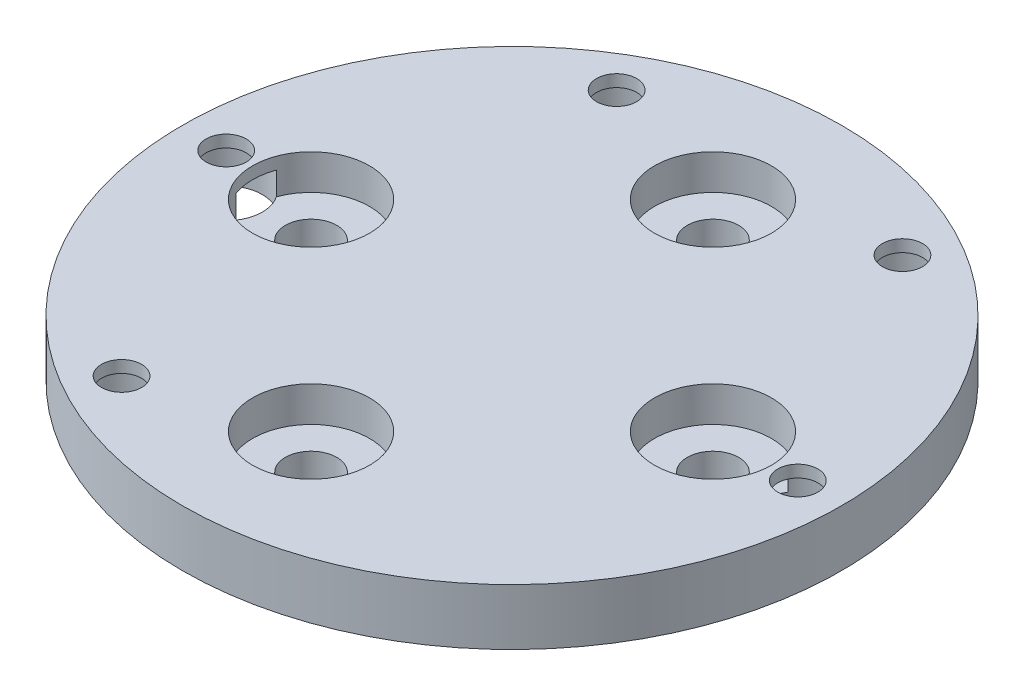
from build123d import *

# Parameters (mm, degrees)
SKETCH1_R                               = 41
BOSS_EXTRUDE1_DEPTH                     = 7
CBORE_FOR_M6_HEX_HEAD_BOLT1_D           = 6.4
CBORE_FOR_M6_HEX_HEAD_BOLT1_CBORE_D     = 14.55
CBORE_FOR_M6_HEX_HEAD_BOLT1_CBORE_DEPTH = 4.38
CIRPATTERN2_COUNT                       = 4
CUT_EXTRUDE4_START                      = -7
SKETCH15_R                              = 2.5
CUT_EXTRUDE4_DEPTH                      = 66.403767002
SKETCH16_R                              = 4.5
CUT_EXTRUDE5_DEPTH                      = 5.5
BOSS_EXTRUDE2_START                     = 7
SKETCH17_R                              = 30
SKETCH17_R_2                            = 3.2
BOSS_EXTRUDE2_DEPTH                     = 7


with BuildPart() as part:
    # Sketch1 → Boss-Extrude1 (new body)
    with BuildSketch(Plane(origin=(0, 0, 0), x_dir=(1, 0, 0), z_dir=(0, 1, 0))):
        with Locations(Location((0, 0, 0), (0, 0, 270))):
            Circle(SKETCH1_R)
    extrude(amount=BOSS_EXTRUDE1_DEPTH)

    # CBORE for M6 Hex Head Bolt1 (through all)
    with Locations(Plane(origin=(0, 7, 0), x_dir=(1, 0, 0), z_dir=(0, 1, 0))):
        with Locations((0, 25)):
            cbore_for_m6_hex_head_bolt1 = CounterBoreHole(CBORE_FOR_M6_HEX_HEAD_BOLT1_D / 2, CBORE_FOR_M6_HEX_HEAD_BOLT1_CBORE_D / 2, CBORE_FOR_M6_HEX_HEAD_BOLT1_CBORE_DEPTH)

    # CirPattern2: CBORE for M6 Hex Head Bolt1 ×4 about axis
    cirpattern2_axis = Axis((0, 0, 0), (0, 1, 0))
    for i in range(1, CIRPATTERN2_COUNT):
        add(cbore_for_m6_hex_head_bolt1.rotate(cirpattern2_axis, i * 360 / CIRPATTERN2_COUNT), mode=Mode.SUBTRACT)

    # Sketch15 → Cut-Extrude4 (cut, through all)
    with BuildSketch(Plane.XZ.offset(CUT_EXTRUDE4_START)):
        with Locations(Location((35.56, 0, 0), (0, 0, 90))):
            Circle(SKETCH15_R)
        with Locations(Location((17.78, -30.795863359, 0), (0, 0, 90))):
            Circle(SKETCH15_R)
        with Locations(Location((-17.78, -30.795863359, 0), (0, 0, 90))):
            Circle(SKETCH15_R)
        with Locations(Location((-35.56, 0, 0), (0, 0, 90))):
            Circle(SKETCH15_R)
        with Locations(Location((-17.78, 30.795863359, 0), (0, 0, 90))):
            Circle(SKETCH15_R)
    extrude(amount=CUT_EXTRUDE4_DEPTH, mode=Mode.SUBTRACT)

    # Sketch16 → Cut-Extrude5 (cut)
    with BuildSketch(Plane.XZ):
        with Locations(Location((-17.78, 30.795863359, 0), (0, 0, 270))):
            Circle(SKETCH16_R)
        with Locations(Location((-35.56, 0, 0), (0, 0, 270))):
            Circle(SKETCH16_R)
        with Locations(Location((35.56, 0, 0), (0, 0, 270))):
            Circle(SKETCH16_R)
        with Locations(Location((-17.78, -30.795863359, 0), (0, 0, 270))):
            Circle(SKETCH16_R)
        with Locations(Location((17.78, -30.795863359, 0), (0, 0, 270))):
            Circle(SKETCH16_R)
    extrude(amount=-CUT_EXTRUDE5_DEPTH, mode=Mode.SUBTRACT)

    # Sketch17 → Boss-Extrude2 (add)
    with BuildSketch(Plane.XZ.offset(BOSS_EXTRUDE2_START)):
        with Locations(Location((0, 0, 0), (0, 0, 90))):
            Circle(SKETCH17_R)
        with Locations(Location((25, 0, 0), (0, 0, 90))):
            Circle(SKETCH17_R_2, mode=Mode.SUBTRACT)
        with Locations(Location((0, -25, 0), (0, 0, 90))):
            Circle(SKETCH17_R_2, mode=Mode.SUBTRACT)
        with Locations(Location((-25, 0, 0), (0, 0, 90))):
            Circle(SKETCH17_R_2, mode=Mode.SUBTRACT)
        with Locations(Location((0, 25, 0), (0, 0, 90))):
            Circle(SKETCH17_R_2, mode=Mode.SUBTRACT)
    extrude(amount=-BOSS_EXTRUDE2_DEPTH)


solid = part.part
